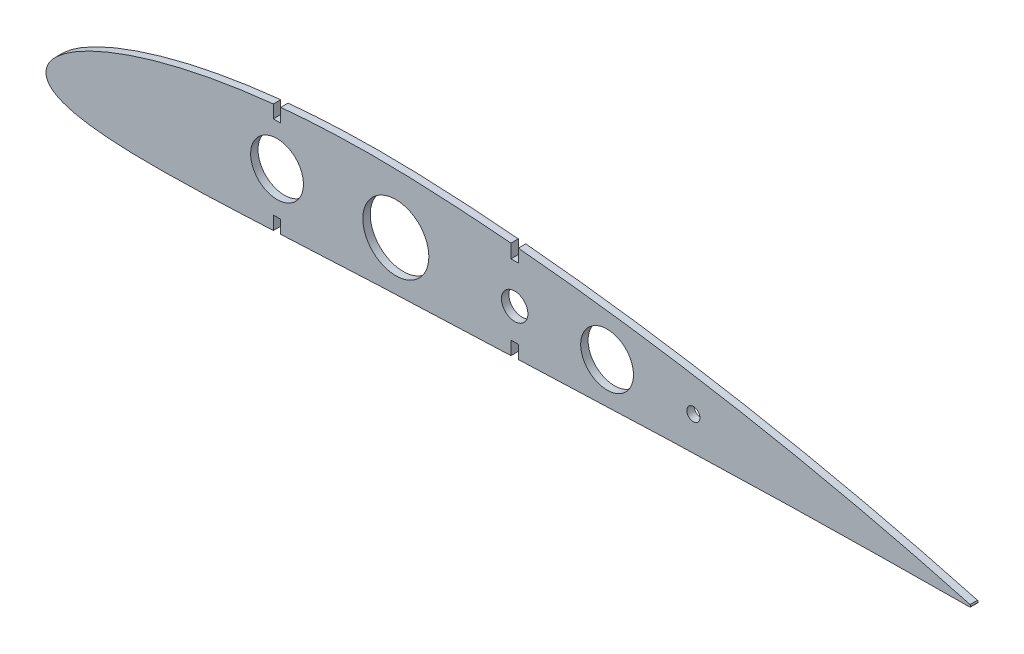
from build123d import *

# Parameters (mm, degrees)
SKETCH_2_R      = 10
SKETCH_2_R_2    = 5
SKETCH_2_R_3    = 12.5
SKETCH_2_R_4    = 2.5
EXTRUDE_1_DEPTH = 1.4


with BuildPart() as part:
    # Эскиз2 → Бобышка-Вытянуть1 (new body, symmetric)
    with BuildSketch(Plane.XY):
        with BuildLine():
            Line((86.1, 32.682283633), (86.1, 27.785621096))
            Line((86.1, 27.785621096), (88.9, 27.785621096))
            Line((88.9, 27.785621096), (88.9, 32.962973681))
            add(Edge.make_bspline(
                [(176.1, 32.045532515), (173.460642448, 32.274383054), (167.786299659, 32.738244602), (159.079993996, 33.354548335), (150.013824851, 33.880339702), (141.037533969, 34.297759375), (132.176453799, 34.561309726), (123.418285188, 34.636133951), (114.728660276, 34.522388831), (106.092728827, 34.217419352), (97.485414888, 33.712894632), (91.763569037, 33.237837821), (88.9, 32.962973681)],
                knots=[0.48932836, 0.48932836, 0.48932836, 0.48932836, 0.51130307, 0.536551515, 0.561723366, 0.586628867, 0.611085431, 0.6352512, 0.659272176, 0.683163753, 0.706922144, 0.730783121, 0.730783121, 0.730783121, 0.730783121], degree=3))
            Line((176.1, 32.045532515), (176.1, 26.882916451))
            Line((176.1, 26.882916451), (178.9, 26.882916451))
            Line((178.9, 26.882916451), (178.9, 31.797856127))
            add(Edge.make_bspline(
                [(350, 0.441), (348.817934836, 0.763027745), (345.408245977, 1.69192274), (339.347864917, 3.301674674), (331.589665686, 5.302675511), (323.091885591, 7.417212373), (314.238285126, 9.538012439), (305.242760894, 11.608254886), (296.187367062, 13.60762908), (287.101376113, 15.529324906), (277.995159278, 17.370991017), (268.873317879, 19.131417094), (259.738667962, 20.809730625), (250.593474588, 22.404766691), (241.439890638, 23.915343362), (232.280043933, 25.339758978), (223.116153021, 26.676302541), (213.950527179, 27.922839844), (204.785615162, 29.076995056), (195.623903708, 30.135946559), (186.99647265, 31.041402296), (181.421156727, 31.570451189), (178.9, 31.797856127)],
                knots=[0, 0, 0, 0, 0.0101622, 0.029313053, 0.052011605, 0.076619468, 0.101948061, 0.127526132, 0.153184131, 0.178867888, 0.204557903, 0.230245712, 0.255925967, 0.281594302, 0.30724642, 0.332878042, 0.358484538, 0.384061186, 0.409602822, 0.435103874, 0.460559416, 0.481556447, 0.481556447, 0.481556447, 0.481556447], degree=3))
            ThreePointArc((350, 0.441), (350.182668182, 0), (350, -0.441))
            add(Edge.make_bspline(
                [(178.9, -4.758637273), (181.652979317, -4.646278606), (187.626173611, -4.403273739), (196.81461857, -4.035333009), (206.460819266, -3.659492142), (216.093643375, -3.297876981), (225.715061788, -2.95311789), (235.327217645, -2.627287704), (244.932209931, -2.322100346), (254.532034352, -2.038929372), (264.128528247, -1.778536728), (273.723303235, -1.541558038), (283.317346051, -1.328064065), (292.909735844, -1.138021673), (302.493517153, -0.971016602), (312.041013985, -0.826421034), (321.464682241, -0.704096652), (330.522295396, -0.604119869), (338.773087678, -0.527128646), (345.182558015, -0.475350241), (348.76868735, -0.44977974), (350, -0.441)],
                knots=[0.517634386, 0.517634386, 0.517634386, 0.517634386, 0.540928595, 0.568176028, 0.595379569, 0.622543445, 0.64967326, 0.676775201, 0.703855228, 0.730918775, 0.757971338, 0.785017763, 0.812061651, 0.839103366, 0.866131651, 0.893099152, 0.919831065, 0.945809917, 0.969680601, 0.989589706, 1, 1, 1, 1], degree=3))
            Line((178.9, -4.758637273), (178.9, 0.224194977))
            Line((178.9, 0.224194977), (176.1, 0.224194977))
            Line((176.1, 0.224194977), (176.1, -4.873020948))
            add(Edge.make_bspline(
                [(88.9, -8.693267562), (89.617844041, -8.657365264), (93.544099689, -8.4603043), (100.675081793, -8.097607246), (110.279925807, -7.615552634), (119.854698054, -7.155331752), (129.404950626, -6.726934654), (138.957043666, -6.344774315), (148.536329767, -5.989584537), (158.156896352, -5.604325894), (167.348797605, -5.231176131), (173.335752744, -4.986028102), (176.1, -4.873020948)],
                knots=[0.263757046, 0.263757046, 0.263757046, 0.263757046, 0.269833583, 0.296993022, 0.324123272, 0.351139107, 0.378035509, 0.404946016, 0.431960837, 0.459078395, 0.4863474, 0.509737017, 0.509737017, 0.509737017, 0.509737017], degree=3))
            Line((88.9, -8.693267562), (88.9, -3.723116029))
            Line((88.9, -3.723116029), (86.1, -3.723116029))
            Line((86.1, -3.723116029), (86.1, -8.832579685))
            add(Edge.make_bspline(
                [(0.067165, 0.869995), (0.031799348, 0.52288612), (-0.038949105, -0.171499965), (0.109187697, -1.238208426), (0.489573911, -2.294373299), (1.140063589, -3.311096493), (2.048873093, -4.254985343), (3.207362223, -5.125399257), (4.62830025, -5.930091469), (6.349357867, -6.683143801), (8.441643964, -7.39506903), (11.016573701, -8.071443347), (14.236363949, -8.71040323), (18.305613464, -9.295466224), (23.419361508, -9.790139433), (29.665932935, -10.146283203), (36.959978182, -10.327294388), (45.07635799, -10.326759678), (53.756929463, -10.166011212), (62.800670475, -9.879297901), (72.081160335, -9.501034945), (79.871929674, -9.138172062), (84.562006059, -8.908655535), (86.1, -8.832579685)],
                knots=[0, 0, 0, 0, 0.002941446, 0.005884319, 0.00901613, 0.012364547, 0.016007934, 0.020036845, 0.024573728, 0.029783835, 0.03589701, 0.04324044, 0.052275965, 0.063634589, 0.077983176, 0.095698161, 0.116520086, 0.13966073, 0.16431217, 0.18991889, 0.216157201, 0.242837762, 0.255856498, 0.255856498, 0.255856498, 0.255856498], degree=3))
            add(Edge.make_bspline(
                [(86.1, 32.682283633), (84.251034658, 32.488999326), (79.618112888, 31.965003077), (72.248067764, 30.96669173), (64.042160436, 29.619190205), (55.994200632, 28.049519945), (48.157087779, 26.258842728), (40.614534945, 24.258661851), (33.496117772, 22.08061089), (26.978950376, 19.787977208), (21.250737748, 17.476669613), (16.436666106, 15.253855393), (12.543120617, 13.201408311), (9.465247652, 11.352044479), (7.047193647, 9.694493277), (5.140372907, 8.19592153), (3.628941572, 6.819827516), (2.433445936, 5.533634041), (1.497819162, 4.313324923), (0.800303575, 3.138270943), (0.302083458, 2.003099556), (0.143157814, 1.236538372), (0.067165, 0.869995)],
                knots=[0.738563451, 0.738563451, 0.738563451, 0.738563451, 0.7539832, 0.77723469, 0.800246382, 0.822950709, 0.845237155, 0.866915896, 0.887662335, 0.906968281, 0.924203157, 0.938878975, 0.950931611, 0.960693484, 0.968646729, 0.975232933, 0.980794744, 0.985583761, 0.989781539, 0.993521313, 0.996902113, 1, 1, 1, 1], degree=3))
        make_face()
        with Locations((87.5, 12.031252534)):
            Circle(SKETCH_2_R, mode=Mode.SUBTRACT)
        with Locations((177.5, 12.031252534)):
            Circle(SKETCH_2_R_2, mode=Mode.SUBTRACT)
        with Locations((132.5, 12.031252534)):
            Circle(SKETCH_2_R_3, mode=Mode.SUBTRACT)
        with Locations((212.5, 12.031252534)):
            Circle(SKETCH_2_R, mode=Mode.SUBTRACT)
        with Locations((245.182668182, 10.487815621)):
            Circle(SKETCH_2_R_4, mode=Mode.SUBTRACT)
    extrude(amount=EXTRUDE_1_DEPTH, both=True)


solid = part.part
